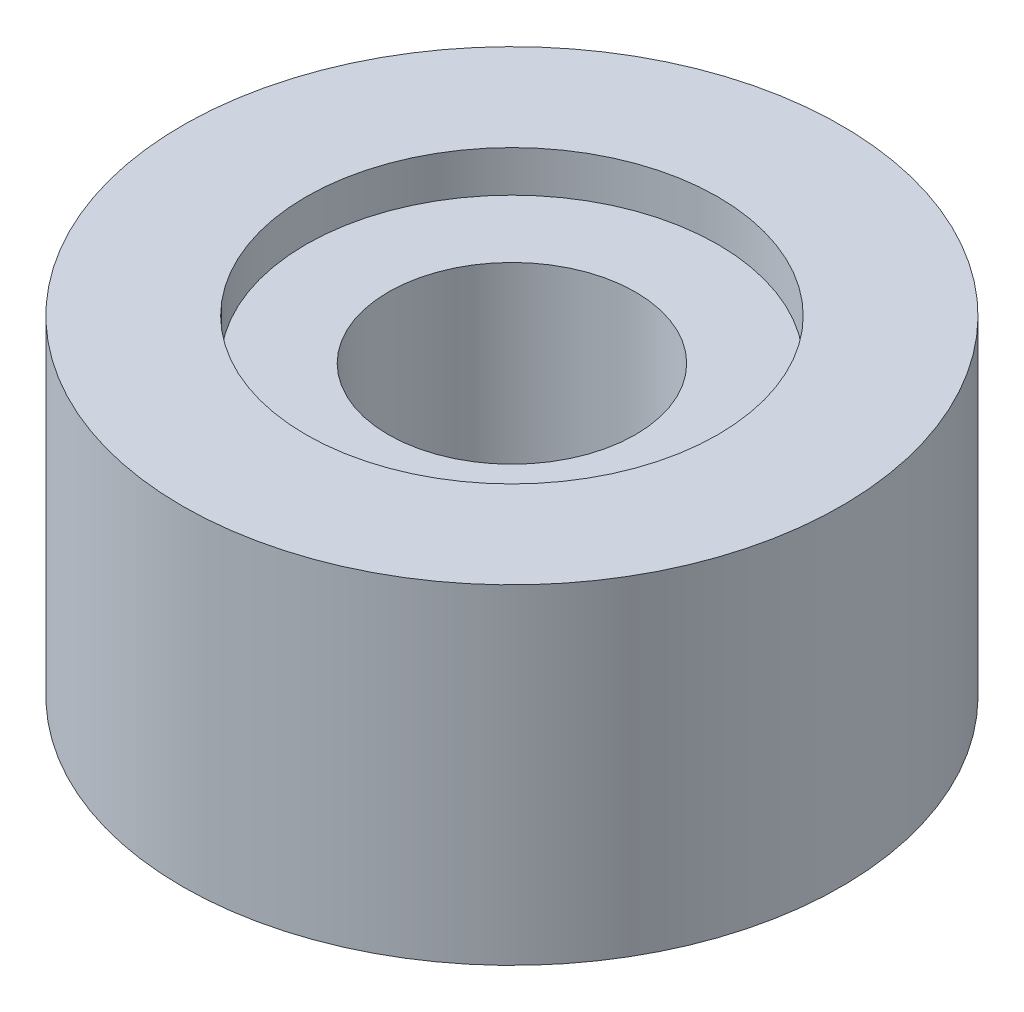
from build123d import *

# Parameters (mm, degrees)
ESQUISSE1_R             = 6
BOSS_EXTRU_1_DEPTH      = 6
ESQUISSE2_R             = 2.25
ENL_V_MAT_EXTRU_1_DEPTH = 5
ESQUISSE3_R             = 3.75
ENL_V_MAT_EXTRU_2_DEPTH = 0.75


with BuildPart() as part:
    # Esquisse1 → Boss.-Extru.1 (new body)
    with BuildSketch(Plane(origin=(0, 0, 0), x_dir=(1, 0, 0), z_dir=(0, 1, 0))):
        Circle(ESQUISSE1_R)
    extrude(amount=BOSS_EXTRU_1_DEPTH)

    # Esquisse2 → Enlèv. mat.-Extru.1 (cut)
    with BuildSketch(Plane(origin=(0, 6, 0), x_dir=(1, 0, 0), z_dir=(0, 1, 0))):
        Circle(ESQUISSE2_R)
    extrude(amount=-ENL_V_MAT_EXTRU_1_DEPTH, mode=Mode.SUBTRACT)

    # Esquisse3 → Enlèv. mat.-Extru.2 (cut)
    with BuildSketch(Plane(origin=(0, 6, 0), x_dir=(1, 0, 0), z_dir=(0, 1, 0))):
        Circle(ESQUISSE3_R)
    extrude(amount=-ENL_V_MAT_EXTRU_2_DEPTH, mode=Mode.SUBTRACT)


solid = part.part
